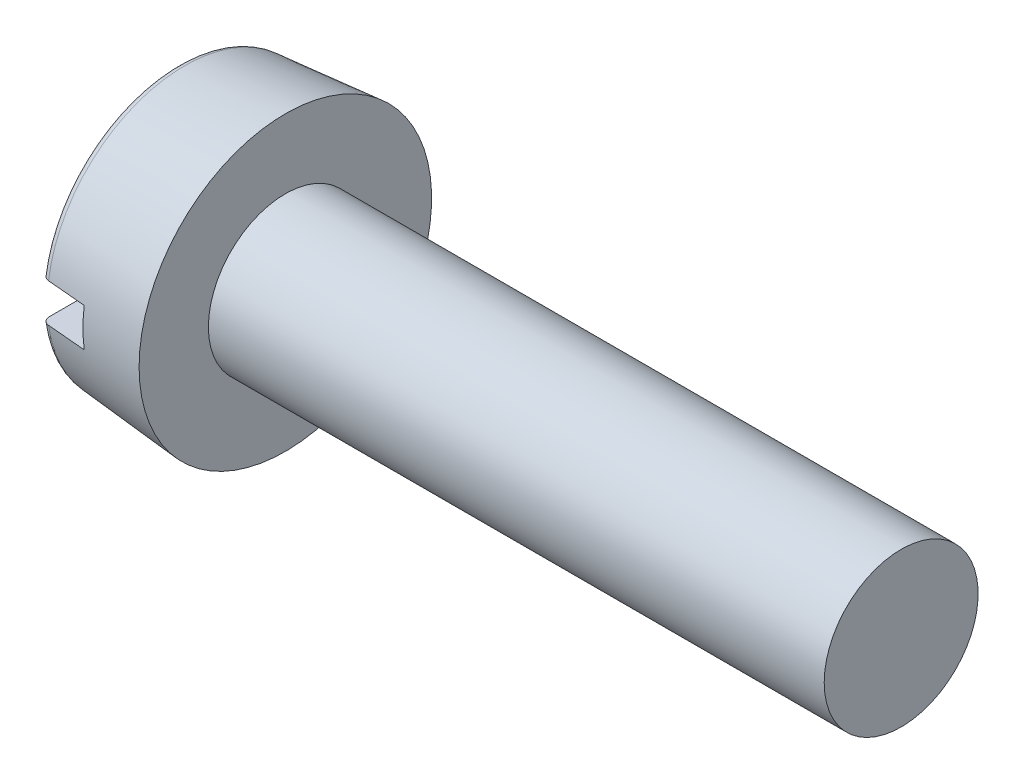
from build123d import *

# Parameters (mm, degrees)
FILLET2_R  = 0.1
SKETCH2_W  = 3.8
SKETCH2_H  = 0.5
SLOT_DEPTH = 0.6


with BuildPart() as part:
    # BodySke → Base-Revolve (revolve)
    with BuildSketch(Plane.XY, mode=Mode.PRIVATE) as base_revolve_sk:
        Polygon((1.4, 1), (1.4, 1.9), (0, 1.777515871), (0, 0), (9.4, 0), (9.4, 1), align=None)
    revolve(base_revolve_sk.sketch.rotate(Axis((-25.4, 0, 0), (1, 0, 0)), 90), axis=Axis((-25.4, 0, 0), (1, 0, 0)))  # turned: the seam where the file's is

    # Fillet2
    fillet2_edges = [part.edges().sort_by_distance(p)[0] for p in [
        (0, 0, -1.777515871),
    ]]
    fillet(fillet2_edges, radius=FILLET2_R)

    # Sketch2 → Slot (cut)
    with BuildSketch(Plane(origin=(0, 0, 0), x_dir=(0, 0, -1), z_dir=(1, 0, 0))):
        Rectangle(SKETCH2_W, SKETCH2_H)
    extrude(amount=SLOT_DEPTH, mode=Mode.SUBTRACT)


solid = part.part
